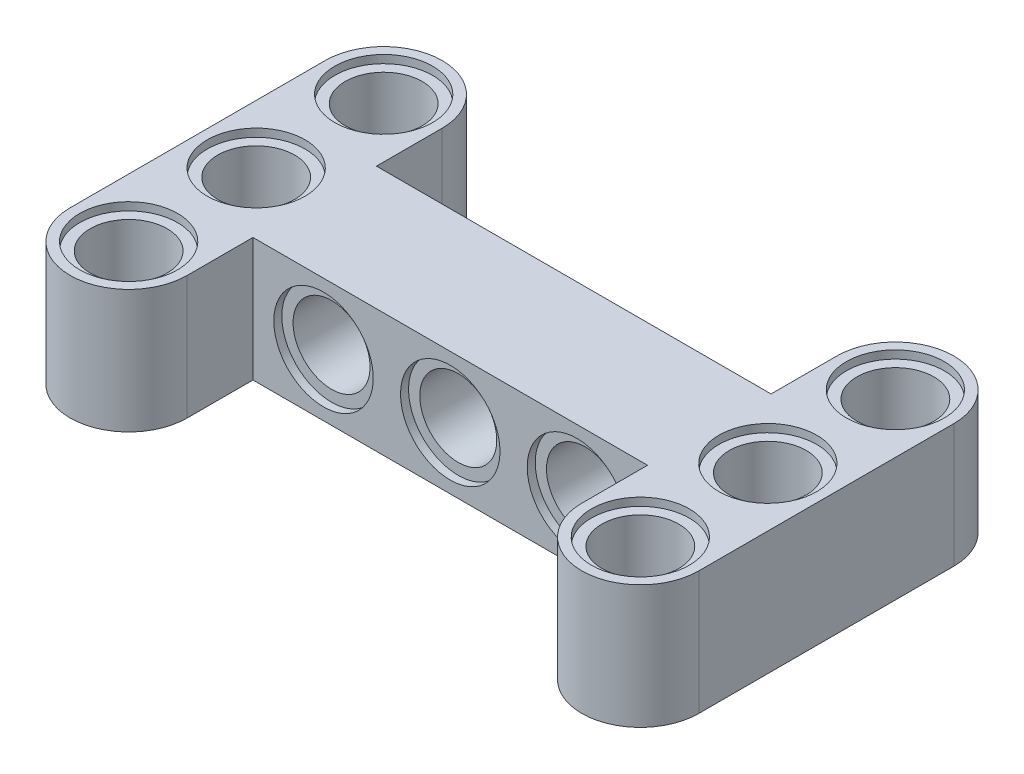
from build123d import *

# Parameters (mm, degrees)
SKETCH1_R           = 2.4
BOSS_EXTRUDE2_DEPTH = 7.7
SKETCH2_R           = 3.05
SKETCH2_R_2         = 2.4
CUT_EXTRUDE3_DEPTH  = 0.5
SKETCH3_R           = 2.4
CUT_EXTRUDE4_DEPTH  = 16.45
SKETCH4_R           = 3.1
SKETCH4_R_2         = 2.4
CUT_EXTRUDE6_DEPTH  = 0.5


with BuildPart() as part:
    # Sketch1 → Boss-Extrude2 (new body)
    with BuildSketch(Plane(origin=(0, 0, 0), x_dir=(1, 0, 0), z_dir=(0, 1, 0))):
        with BuildLine():
            Line((19.6, 4.1), (19.6, -11.8))
            ThreePointArc((19.6, -11.8), (15.95, -15.45), (12.3, -11.8))
            Line((12.3, -11.8), (12.3, -7.7))
            Line((12.3, -7.7), (-12.3, -7.7))
            Line((-12.3, -7.7), (-12.3, -11.8))
            ThreePointArc((-12.3, -11.8), (-15.95, -15.45), (-19.6, -11.8))
            Line((-19.6, -11.8), (-19.6, 4.1))
            ThreePointArc((-19.6, 4.1), (-15.95, 7.75), (-12.3, 4.1))
            Line((-12.3, 4.1), (-12.3, 0))
            Line((-12.3, 0), (12.3, 0))
            Line((12.3, 0), (12.3, 4.1))
            ThreePointArc((12.3, 4.1), (15.95, 7.75), (19.6, 4.1))
        make_face()
        with Locations((15.95, 4.1)):
            Circle(SKETCH1_R, mode=Mode.SUBTRACT)
        with Locations((15.95, -3.85)):
            Circle(SKETCH1_R, mode=Mode.SUBTRACT)
        with Locations((15.95, -11.8)):
            Circle(SKETCH1_R, mode=Mode.SUBTRACT)
        with Locations((-15.95, -11.8)):
            Circle(SKETCH1_R, mode=Mode.SUBTRACT)
        with Locations((-15.95, -3.85)):
            Circle(SKETCH1_R, mode=Mode.SUBTRACT)
        with Locations((-15.95, 4.1)):
            Circle(SKETCH1_R, mode=Mode.SUBTRACT)
    extrude(amount=BOSS_EXTRUDE2_DEPTH)

    # Sketch2 → Cut-Extrude3 (cut)
    with BuildSketch(Plane(origin=(0, 7.7, 0), x_dir=(1, 0, 0), z_dir=(0, 1, 0))):
        with Locations((-15.95, 4.1)):
            Circle(SKETCH2_R)
        with Locations((-15.95, 4.1)):
            Circle(SKETCH2_R_2, mode=Mode.SUBTRACT)
        with Locations((-15.95, -3.85)):
            Circle(SKETCH2_R)
        with Locations((-15.95, -3.85)):
            Circle(SKETCH2_R_2, mode=Mode.SUBTRACT)
        with Locations((-15.95, -11.8)):
            Circle(SKETCH2_R)
        with Locations((-15.95, -11.8)):
            Circle(SKETCH2_R_2, mode=Mode.SUBTRACT)
        with Locations((15.95, -3.85)):
            Circle(SKETCH2_R)
        with Locations((15.95, -3.85)):
            Circle(SKETCH2_R_2, mode=Mode.SUBTRACT)
        with Locations((15.95, 4.1)):
            Circle(SKETCH2_R)
        with Locations((15.95, 4.1)):
            Circle(SKETCH2_R_2, mode=Mode.SUBTRACT)
        with Locations((15.95, -11.8)):
            Circle(SKETCH2_R)
        with Locations((15.95, -11.8)):
            Circle(SKETCH2_R_2, mode=Mode.SUBTRACT)
    cut_extrude3 = extrude(amount=-CUT_EXTRUDE3_DEPTH, mode=Mode.SUBTRACT)

    # Sketch3 → Cut-Extrude4 (cut, through all)
    with BuildSketch(Plane(origin=(0, 0, 0), x_dir=(-1, 0, 0), z_dir=(0, 0, -1))):
        with Locations((7.9, 3.85)):
            Circle(SKETCH3_R)
        with Locations((0, 3.85)):
            Circle(SKETCH3_R)
        with Locations((-7.9, 3.85)):
            Circle(SKETCH3_R)
    extrude(amount=-CUT_EXTRUDE4_DEPTH, mode=Mode.SUBTRACT)

    # Sketch4 → Cut-Extrude6 (cut)
    with BuildSketch(Plane(origin=(0, 0, 0), x_dir=(-1, 0, 0), z_dir=(0, 0, -1))):
        with Locations((-7.9, 3.85)):
            Circle(SKETCH4_R)
        with Locations((-7.9, 3.85)):
            Circle(SKETCH4_R_2, mode=Mode.SUBTRACT)
        with Locations((0, 3.85)):
            Circle(SKETCH4_R)
        with Locations((0, 3.85)):
            Circle(SKETCH4_R_2, mode=Mode.SUBTRACT)
        with Locations((7.9, 3.85)):
            Circle(SKETCH4_R)
        with Locations((7.9, 3.85)):
            Circle(SKETCH4_R_2, mode=Mode.SUBTRACT)
    cut_extrude6 = extrude(amount=-CUT_EXTRUDE6_DEPTH, mode=Mode.SUBTRACT)

    # Mirror1: Cut-Extrude6 across plane
    add(cut_extrude6.mirror(Plane(origin=(0, 0, 3.85), x_dir=(1, 0, 0), z_dir=(0, 0, -1))), mode=Mode.SUBTRACT)

    # Mirror2: Cut-Extrude3 across plane
    add(cut_extrude3.mirror(Plane.ZX.offset(3.85)), mode=Mode.SUBTRACT)


solid = part.part
